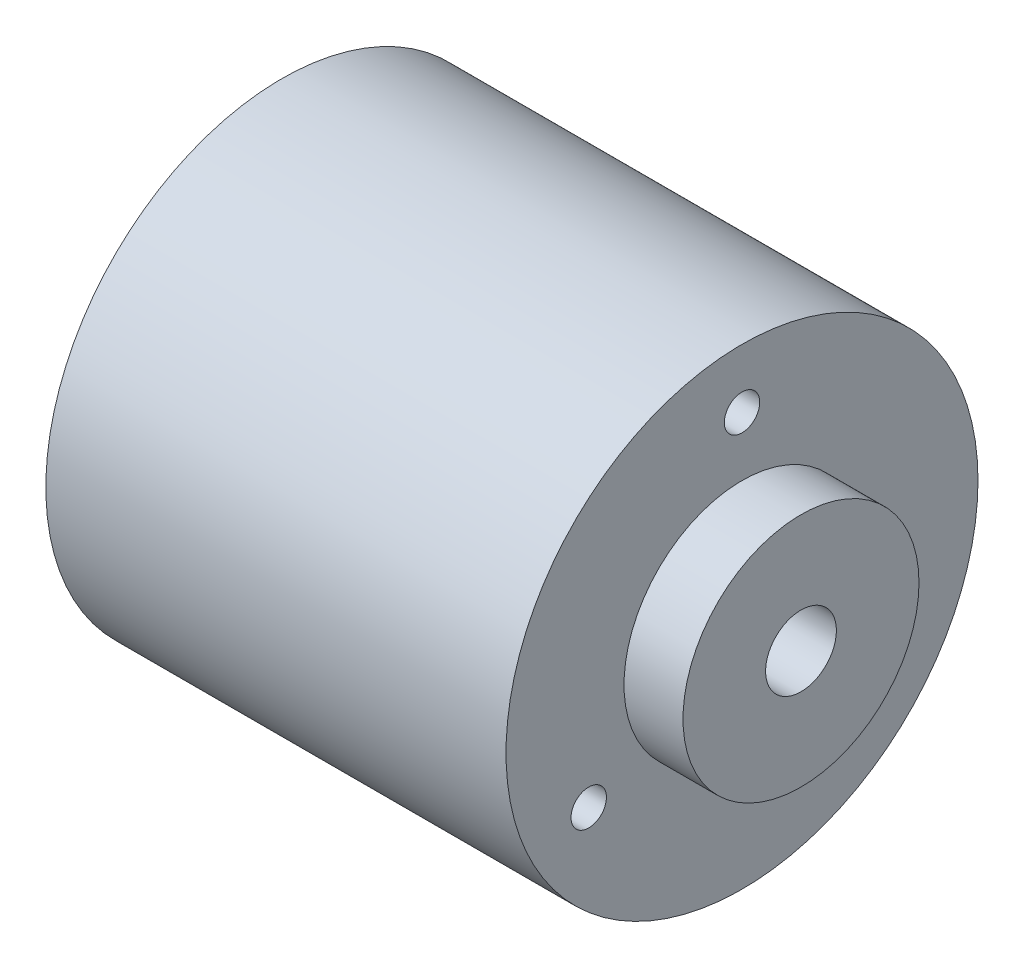
from build123d import *

# Parameters (mm, degrees)
SKETCH1_R                 = 20
BOSS_EXTRUDE1_DEPTH       = 39
SKETCH2_R                 = 10
BOSS_EXTRUDE2_DEPTH       = 5
F_3_0MM_DOWEL_HOLE1_D     = 3
F_3_0MM_DOWEL_HOLE1_DEPTH = 7
F_3_0MM_DOWEL_HOLE1_TIP   = 0.901290929
SKETCH3_R                 = 3
CUT_EXTRUDE2_DEPTH        = 5


with BuildPart() as part:
    # Sketch1 → Boss-Extrude1 (new body)
    with BuildSketch(Plane(origin=(0, 0, 0), x_dir=(0, 0, -1), z_dir=(1, 0, 0))):
        Circle(SKETCH1_R)
    extrude(amount=BOSS_EXTRUDE1_DEPTH)

    # Sketch2 → Boss-Extrude2 (add)
    with BuildSketch(Plane(origin=(39, 0, 0), x_dir=(0, 0, -1), z_dir=(1, 0, 0))):
        Circle(SKETCH2_R)
    extrude(amount=BOSS_EXTRUDE2_DEPTH)

    # Ø3.0mm Dowel Hole1
    with Locations(Plane(origin=(39, 15, 0), x_dir=(0, 0, 1), z_dir=(1, 0, 0))):
        with Locations((0, 0), (-12.990381057, 22.5), (12.990381057, 22.5)):
            Hole(F_3_0MM_DOWEL_HOLE1_D / 2, depth=F_3_0MM_DOWEL_HOLE1_DEPTH)
            with Locations((0, 0, -(F_3_0MM_DOWEL_HOLE1_DEPTH + F_3_0MM_DOWEL_HOLE1_TIP / 2))):  # 118° drill point
                Cone(0, F_3_0MM_DOWEL_HOLE1_D / 2, F_3_0MM_DOWEL_HOLE1_TIP, mode=Mode.SUBTRACT)

    # Sketch3 → Cut-Extrude2 (cut)
    with BuildSketch(Plane(origin=(44, 0, 0), x_dir=(0, 0, -1), z_dir=(1, 0, 0))):
        Circle(SKETCH3_R)
    extrude(amount=-CUT_EXTRUDE2_DEPTH, mode=Mode.SUBTRACT)


solid = part.part
